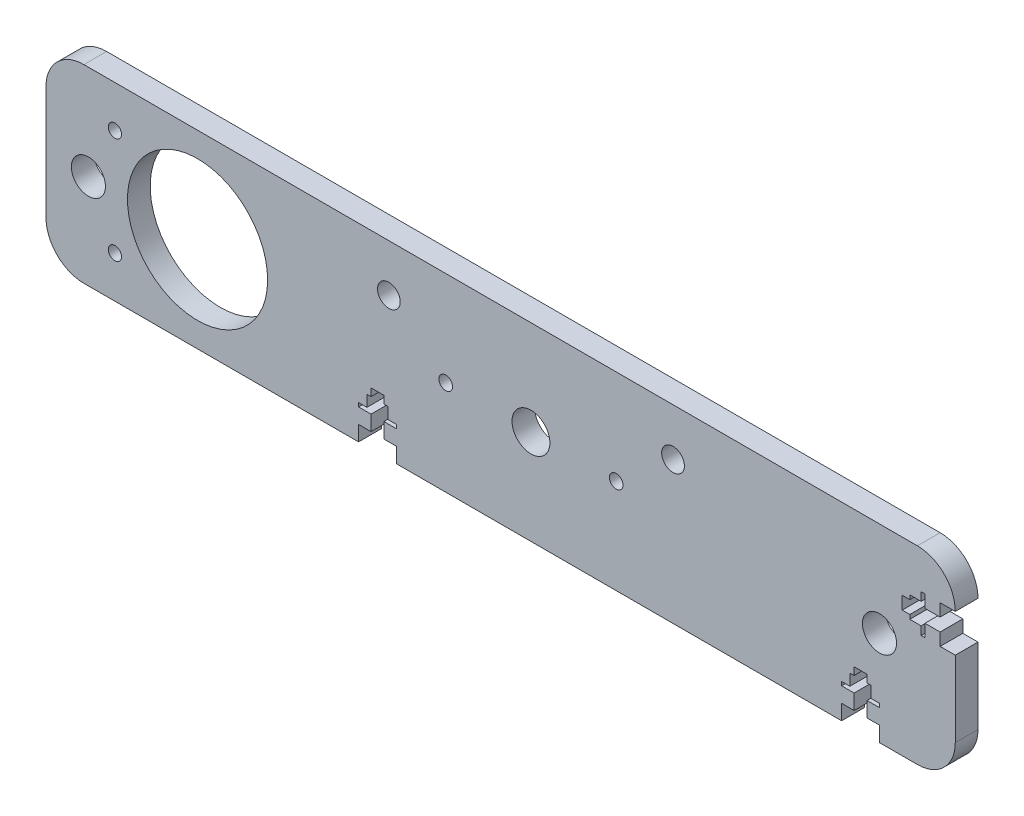
from build123d import *

# Parameters (mm, degrees)
ESBO_O1_R                = 18.5
ESBO_O1_R_2              = 4.5
ESBO_O1_R_3              = 5
ESBO_O1_R_4              = 1.8
ESBO_O1_R_5              = 3
ESBO_O1_R_6              = 1.75
RESSALTO_EXTRUS_O1_DEPTH = 6


with BuildPart() as part:
    # Esboço1 → Ressalto-extrusão1 (new body)
    with BuildSketch(Plane.XY):
        with BuildLine():
            Line((100, -25), (100, -21))
            Line((100, -21), (96.7, -21))
            Line((96.7, -21), (96.7, -17))
            Line((96.7, -17), (100, -17))
            Line((100, -17), (100, -16))
            Line((100, -16), (97.8, -16))
            Line((97.8, -16), (97.8, -13))
            Line((97.8, -13), (96.7, -13))
            Line((96.7, -13), (96.7, -11))
            Line((96.7, -11), (93.3, -11))
            Line((93.3, -11), (93.3, -13))
            Line((93.3, -13), (92.2, -13))
            Line((92.2, -13), (92.2, -16))
            Line((92.2, -16), (90, -16))
            Line((90, -16), (90, -17))
            Line((90, -17), (93.3, -17))
            Line((93.3, -17), (93.3, -21))
            Line((93.3, -21), (90, -21))
            Line((90, -21), (90, -25))
            Line((90, -25), (-27.5, -25))
            Line((-27.5, -25), (-27.5, -21))
            Line((-27.5, -21), (-30.8, -21))
            Line((-30.8, -21), (-30.8, -17))
            Line((-30.8, -17), (-27.5, -17))
            Line((-27.5, -17), (-27.5, -16))
            Line((-27.5, -16), (-29.7, -16))
            Line((-29.7, -16), (-29.7, -13))
            Line((-29.7, -13), (-30.8, -13))
            Line((-30.8, -13), (-30.8, -11))
            Line((-30.8, -11), (-34.2, -11))
            Line((-34.2, -11), (-34.2, -13))
            Line((-34.2, -13), (-35.3, -13))
            Line((-35.3, -13), (-35.3, -16))
            Line((-35.3, -16), (-37.5, -16))
            Line((-37.5, -16), (-37.5, -17))
            Line((-37.5, -17), (-34.2, -17))
            Line((-34.2, -17), (-34.2, -21))
            Line((-34.2, -21), (-37.5, -21))
            Line((-37.5, -21), (-37.5, -25))
            Line((-37.5, -25), (-110, -25))
            ThreePointArc((-110, -25), (-117.071067812, -22.071067812), (-120, -15))
            Line((-120, -15), (-120, 15))
            ThreePointArc((-120, 15), (-117.071067812, 22.071067812), (-110, 25))
            Line((-110, 25), (110, 25))
            ThreePointArc((110, 25), (117.071067812, 22.071067812), (120, 15))
            Line((120, 15), (116, 15))
            Line((116, 15), (116, 11.7))
            Line((116, 11.7), (112, 11.7))
            Line((112, 11.7), (112, 15))
            Line((112, 15), (111, 15))
            Line((111, 15), (111, 12.8))
            Line((111, 12.8), (108, 12.8))
            Line((108, 12.8), (108, 11.7))
            Line((108, 11.7), (106, 11.7))
            Line((106, 11.7), (106, 8.3))
            Line((106, 8.3), (108, 8.3))
            Line((108, 8.3), (108, 7.2))
            Line((108, 7.2), (111, 7.2))
            Line((111, 7.2), (111, 5))
            Line((111, 5), (112, 5))
            Line((112, 5), (112, 8.3))
            Line((112, 8.3), (116, 8.3))
            Line((116, 8.3), (116, 5))
            Line((116, 5), (120, 5))
            Line((120, 5), (120, -15))
            ThreePointArc((120, -15), (117.071067812, -22.071067812), (110, -25))
            Line((110, -25), (100, -25))
        make_face()
        with Locations((-80, 0)):
            Circle(ESBO_O1_R, mode=Mode.SUBTRACT)
        with Locations((100, 0)):
            Circle(ESBO_O1_R_2, mode=Mode.SUBTRACT)
        with Locations((8, 0)):
            Circle(ESBO_O1_R_3, mode=Mode.SUBTRACT)
        with Locations((-108.81, 0)):
            Circle(ESBO_O1_R_2, mode=Mode.SUBTRACT)
        with Locations((-14.5, 0)):
            Circle(ESBO_O1_R_4, mode=Mode.SUBTRACT)
        with Locations((30.5, 0)):
            Circle(ESBO_O1_R_4, mode=Mode.SUBTRACT)
        with Locations((-29.5, 12.5)):
            Circle(ESBO_O1_R_5, mode=Mode.SUBTRACT)
        with Locations((45.5, 12.5)):
            Circle(ESBO_O1_R_5, mode=Mode.SUBTRACT)
        with Locations((-101.81, 14)):
            Circle(ESBO_O1_R_6, mode=Mode.SUBTRACT)
        with Locations((-101.81, -14)):
            Circle(ESBO_O1_R_6, mode=Mode.SUBTRACT)
    extrude(amount=RESSALTO_EXTRUS_O1_DEPTH)


solid = part.part
